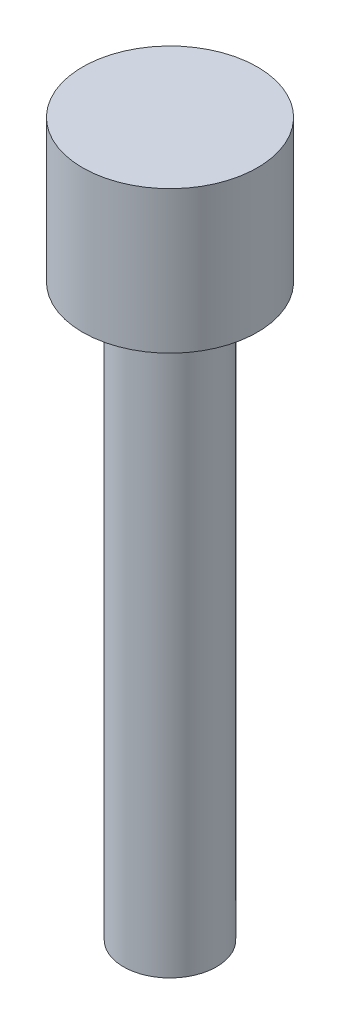
from build123d import *

# Parameters (mm, degrees)
SKETCH1_R           = 1.84
BOSS_EXTRUDE1_DEPTH = 3
SKETCH2_R           = 0.98
BOSS_EXTRUDE2_DEPTH = 12


with BuildPart() as part:
    # Sketch1 → Boss-Extrude1 (new body)
    with BuildSketch(Plane(origin=(0, 0, 0), x_dir=(1, 0, 0), z_dir=(0, 1, 0))):
        Circle(SKETCH1_R)
    extrude(amount=BOSS_EXTRUDE1_DEPTH)

    # Sketch2 → Boss-Extrude2 (add)
    with BuildSketch(Plane.XZ):
        Circle(SKETCH2_R)
    extrude(amount=BOSS_EXTRUDE2_DEPTH)


solid = part.part
